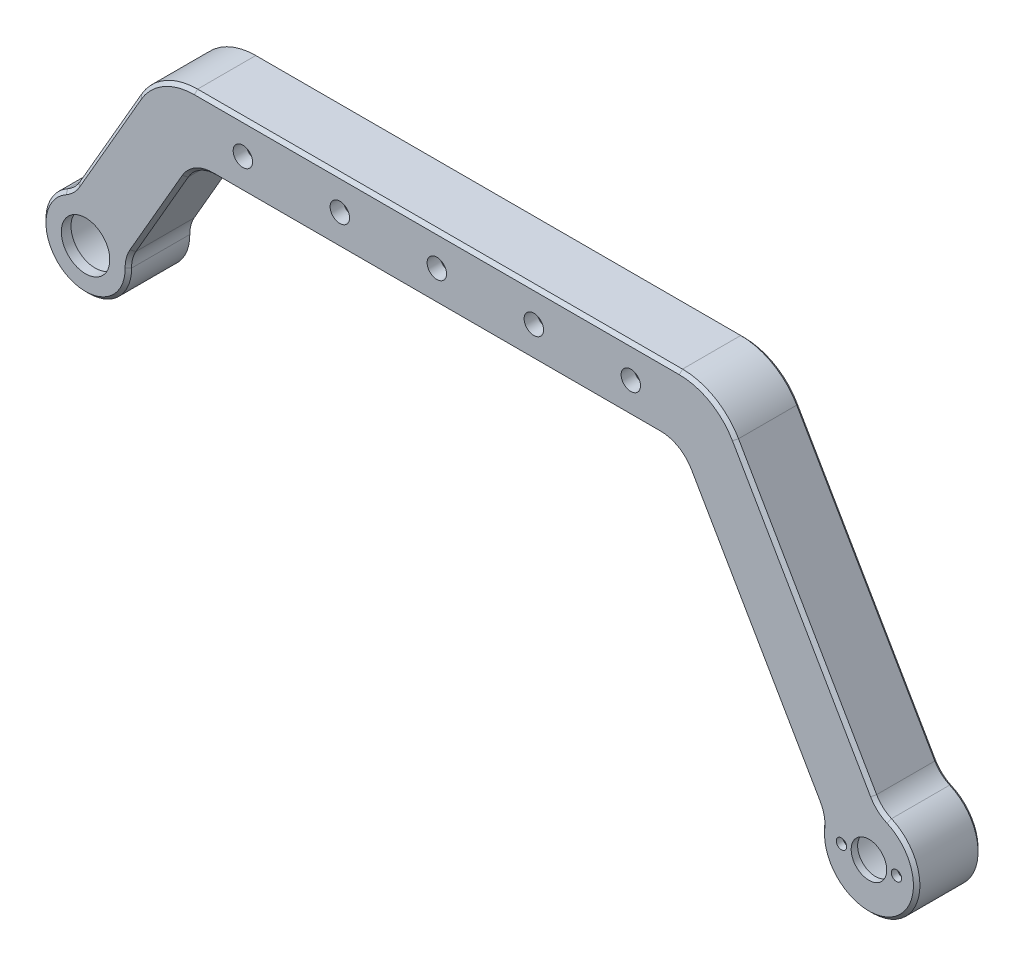
from build123d import *

# Parameters (mm, degrees)
SKETCH1_R               = 1.6
BOSS_EXTRUDE1_DEPTH     = 10
SKETCH2_R               = 11.25
SKETCH2_R_2             = 12.75
CUT_EXTRUDE1_DEPTH      = 177.242290049
CUT_EXTRUDE1_DEPTH_BACK = 177.242290049
BOSS_EXTRUDE2_START     = -10
SKETCH2_3_R             = 13.25
SKETCH2_3_R_2           = 11.25
BOSS_EXTRUDE2_DEPTH     = 20
BOSS_EXTRUDE3_START     = 10
SKETCH2_4_R             = 11.25
SKETCH2_4_R_2           = 7.5
BOSS_EXTRUDE3_DEPTH     = 3
BOSS_EXTRUDE4_START     = -10
SKETCH2_5_R             = 14.75
SKETCH2_5_R_2           = 12.75
BOSS_EXTRUDE4_DEPTH     = 20
BOSS_EXTRUDE5_START     = 10
SKETCH2_6_R             = 12.75
SKETCH2_6_R_2           = 1.6
SKETCH2_6_R_3           = 5.5
BOSS_EXTRUDE5_DEPTH     = 2
FILLET1_R               = 10
CUT_EXTRUDE2_START      = 10
SKETCH3_R               = 3
CUT_EXTRUDE2_DEPTH      = 4
CHAMFER1_SIZE           = 1


with BuildPart() as part:
    # Sketch1 → Boss-Extrude1 (new, symmetric)
    with BuildSketch(Plane.XY):
        with BuildLine():
            Line((-75, -10), (75, -10))
            Line((75, -10), (125, -96.602540378))
            ThreePointArc((125, -96.602540378), (138.660254038, -100.262794416), (142.320508076, -86.602540378))
            Line((142.320508076, -86.602540378), (92.320508076, 0))
            ThreePointArc((92.320508076, 0), (85, 7.320508076), (75, 10))
            Line((75, 10), (-75, 10))
            ThreePointArc((-75, 10), (-85, 7.320508076), (-92.320508076, 0))
            Line((-92.320508076, 0), (-117.320508076, -43.301270189))
            ThreePointArc((-117.320508076, -43.301270189), (-113.660254038, -56.961524227), (-100, -53.301270189))
            Line((-100, -53.301270189), (-75, -10))
        make_face()
        Circle(SKETCH1_R, mode=Mode.SUBTRACT)
        with Locations((-60, 0)):
            Circle(SKETCH1_R, mode=Mode.SUBTRACT)
        with Locations((-30, 0)):
            Circle(SKETCH1_R, mode=Mode.SUBTRACT)
        with Locations((30, 0)):
            Circle(SKETCH1_R, mode=Mode.SUBTRACT)
        with Locations((60, 0)):
            Circle(SKETCH1_R, mode=Mode.SUBTRACT)
    extrude(amount=BOSS_EXTRUDE1_DEPTH, both=True)

    # Sketch2 → Cut-Extrude1 (cut, two sides)
    with BuildSketch(Plane.XY) as cut_extrude1_sk:
        with Locations((-108.660254038, -48.301270189)):
            Circle(SKETCH2_R)
        with Locations((133.660254038, -91.602540378)):
            Circle(SKETCH2_R_2)
    extrude(amount=CUT_EXTRUDE1_DEPTH, mode=Mode.SUBTRACT)
    extrude(cut_extrude1_sk.sketch, amount=-CUT_EXTRUDE1_DEPTH_BACK, mode=Mode.SUBTRACT)

    # Sketch2_3 → Boss-Extrude2 (add)
    with BuildSketch(Plane.XY.offset(BOSS_EXTRUDE2_START)):
        with Locations((-108.660254038, -48.301270189)):
            Circle(SKETCH2_3_R)
        with Locations((-108.660254038, -48.301270189)):
            Circle(SKETCH2_3_R_2, mode=Mode.SUBTRACT)
    extrude(amount=BOSS_EXTRUDE2_DEPTH)

    # Sketch2_4 → Boss-Extrude3 (add)
    with BuildSketch(Plane.XY.offset(BOSS_EXTRUDE3_START)):
        with Locations((-108.660254038, -48.301270189)):
            Circle(SKETCH2_4_R)
        with Locations(Location((-108.660254038, -48.301270189, 0), (0, 0, 180))):
            Circle(SKETCH2_4_R_2, mode=Mode.SUBTRACT)
    extrude(amount=-BOSS_EXTRUDE3_DEPTH)

    # Sketch2_5 → Boss-Extrude4 (add)
    with BuildSketch(Plane.XY.offset(BOSS_EXTRUDE4_START)):
        with Locations((133.660254038, -91.602540378)):
            Circle(SKETCH2_5_R)
        with Locations((133.660254038, -91.602540378)):
            Circle(SKETCH2_5_R_2, mode=Mode.SUBTRACT)
    extrude(amount=BOSS_EXTRUDE4_DEPTH)

    # Sketch2_6 → Boss-Extrude5 (add)
    with BuildSketch(Plane.XY.offset(BOSS_EXTRUDE5_START)):
        with Locations((133.660254038, -91.602540378)):
            Circle(SKETCH2_6_R)
        with Locations(Location((125.160254038, -91.602540378, 0), (0, 0, 180))):
            Circle(SKETCH2_6_R_2, mode=Mode.SUBTRACT)
        with Locations(Location((133.660254038, -91.602540378, 0), (0, 0, 180))):
            Circle(SKETCH2_6_R_3, mode=Mode.SUBTRACT)
        with Locations(Location((142.160254038, -91.602540378, 0), (0, 0, 180))):
            Circle(SKETCH2_6_R_2, mode=Mode.SUBTRACT)
    extrude(amount=-BOSS_EXTRUDE5_DEPTH)

    # Fillet1
    fillet1_edges = [part.edges().sort_by_distance(p)[0] for p in [
        (136.899195965, -77.212552359, 0),
        (119.578687889, -87.212552359, 0),
        (75, -10, 0),
        (-75, -10, 0),
        (-112.974173413, -35.773197727, 0),
        (-95.653665337, -45.773197727, 0),
    ]]
    fillet(fillet1_edges, radius=FILLET1_R)

    # Sketch3 → Cut-Extrude2 (cut)
    with BuildSketch(Plane.XY.offset(CUT_EXTRUDE2_START)):
        with Locations(Location((-60, 0, 0), (0, 0, 180))):
            Circle(SKETCH3_R)
        with Locations(Location((-30, 0, 0), (0, 0, 180))):
            Circle(SKETCH3_R)
        with Locations(Location((0, 0, 0), (0, 0, 180))):
            Circle(SKETCH3_R)
        with Locations(Location((30, 0, 0), (0, 0, 180))):
            Circle(SKETCH3_R)
        with Locations(Location((60, 0, 0), (0, 0, 180))):
            Circle(SKETCH3_R)
    extrude(amount=-CUT_EXTRUDE2_DEPTH, mode=Mode.SUBTRACT)

    # Chamfer1
    chamfer1_edges = [part.edges().sort_by_distance(p)[0] for p in [
        (-101.85653165, -16.516877333, -10),
        (-85, 7.320508076, -10),
        (0, 10, -10),
        (85, 7.320508076, -10),
        (141.035254038, -104.376415084, 10),
        (141.035254038, -104.376415084, -10),
        (113.675627248, -36.988151408, -10),
        (113.675627248, -36.988151408, 10),
        (-115.285254038, -59.776106789, -10),
        (-115.285254038, -59.776106789, 10),
        (-85.979399248, -29.016877333, -10),
        (-85.979399248, -29.016877333, 10),
        (97.798494845, -49.488151408, 10),
        (97.798494845, -49.488151408, -10),
        (0, -10, -10),
        (0, -10, 10),
        (137.005608205, -76.413071632, 10),
        (137.005608205, -76.413071632, -10),
        (-113.022539154, -35.145386139, -10),
        (-113.022539154, -35.145386139, 10),
        (-95.085781683, -45.501177894, 10),
        (-95.085781683, -45.501177894, -10),
        (118.83311115, -86.904967699, -10),
        (118.83311115, -86.904967699, 10),
        (74.226497308, -11.339745962, -10),
        (74.226497308, -11.339745962, 10),
        (-74.226497308, -11.339745962, -10),
        (-74.226497308, -11.339745962, 10),
        (85, 7.320508076, 10),
        (0, 10, 10),
        (-85, 7.320508076, 10),
        (-101.85653165, -16.516877333, 10),
    ]]
    chamfer(chamfer1_edges, length=CHAMFER1_SIZE)


solid = part.part
